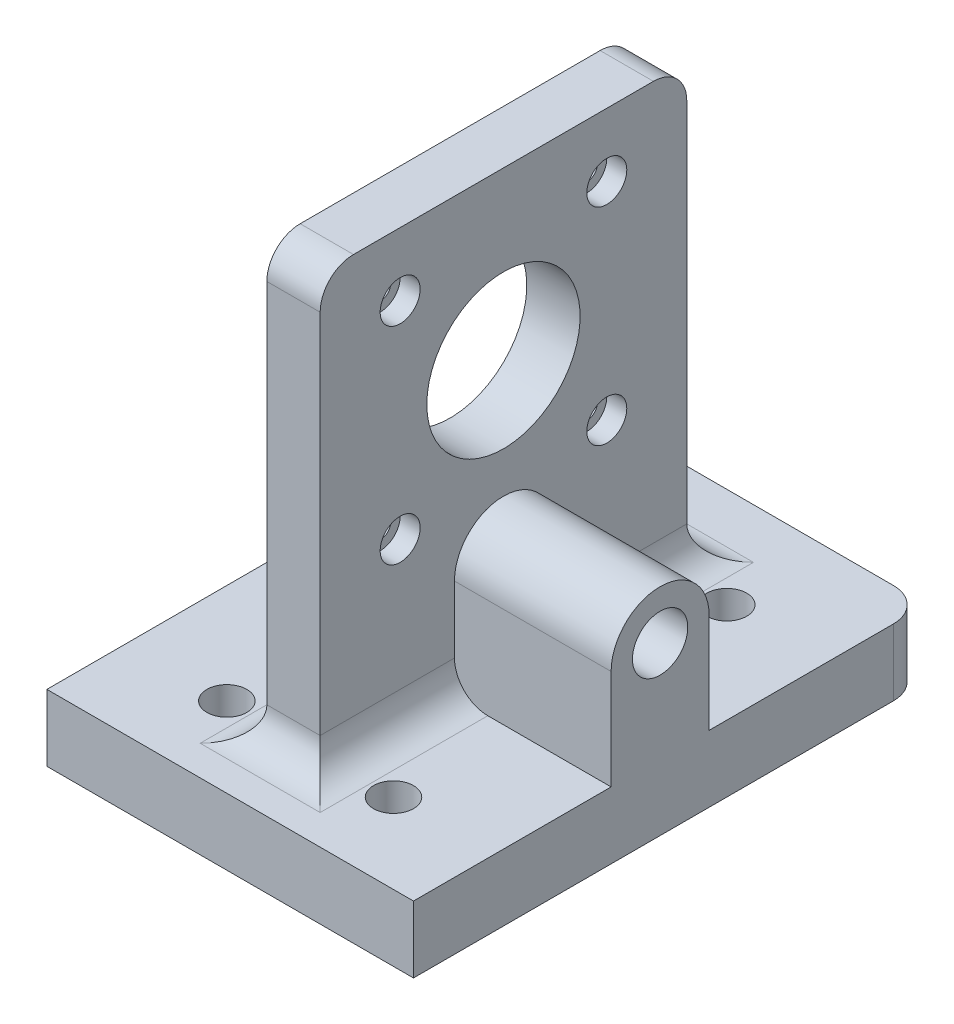
from build123d import *

# Parameters (mm, degrees)
SKETCH1_W               = 55
SKETCH1_H               = 80
BOSS_EXTRUDE1_DEPTH     = 10
SKETCH6_R               = 1.65
CUT_EXTRUDE2_DEPTH      = 55
LPATTERN1_COUNT         = 3
LPATTERN1_PITCH         = 25
MIRROR3_COPY_1_SKETCH_R = 1.65
MIRROR3_COPY_1_DEPTH    = 55
MIRROR3_COPY_2_SKETCH_R = 1.65
MIRROR3_COPY_2_DEPTH    = 55
SKETCH8_W               = 8
SKETCH8_H               = 55
BOSS_EXTRUDE3_DEPTH     = 65
FILLET3_R               = 5
SKETCH9_R               = 1.6
SKETCH9_R_2             = 11.5
CUT_EXTRUDE3_DEPTH      = 32.5
SKETCH10_R              = 3
CUT_EXTRUDE4_DEPTH      = 3
CUT_EXTRUDE5_START      = -5
SKETCH11_R              = 3
CUT_EXTRUDE5_DEPTH      = 71
LPATTERN2_COUNT         = 3
LPATTERN2_PITCH         = 25
MIRROR4_START           = -5
MIRROR4_COPY_1_SKETCH_R = 3
MIRROR4_COPY_1_DEPTH    = 71
MIRROR4_COPY_2_SKETCH_R = 3
MIRROR4_COPY_2_DEPTH    = 71
CUT_EXTRUDE6_DEPTH      = 10
SKETCH13_R              = 4.15
BOSS_EXTRUDE4_DEPTH     = 23.5


with BuildPart() as part:
    # Sketch1 → Boss-Extrude1 (new body)
    with BuildSketch(Plane(origin=(0, 0, 0), x_dir=(1, 0, 0), z_dir=(0, 1, 0))):
        Rectangle(SKETCH1_W, SKETCH1_H)
    extrude(amount=BOSS_EXTRUDE1_DEPTH)

    # Sketch6 → Cut-Extrude2 (cut)
    with BuildSketch(Plane(origin=(0, 10, 0), x_dir=(1, 0, 0), z_dir=(0, 1, 0))):
        with Locations((-12.5, -25)):
            Circle(SKETCH6_R)
    cut_extrude2 = extrude(amount=-CUT_EXTRUDE2_DEPTH, mode=Mode.SUBTRACT)

    # LPattern1: Cut-Extrude2 ×3
    with Locations(*[(0, 0, -i * LPATTERN1_PITCH) for i in range(1, LPATTERN1_COUNT)]):
        add(cut_extrude2, mode=Mode.SUBTRACT)

    # Mirror3: Cut-Extrude2 across plane
    add(cut_extrude2.mirror(Plane(origin=(0, 0, 0), x_dir=(0, 0, 1), z_dir=(1, 0, 0))), mode=Mode.SUBTRACT)

    # Mirror3 copy 1 sketch → Mirror3 copy 1 (cut)
    with BuildSketch(Plane(origin=(0, 10, -25), x_dir=(-1, 0, 0), z_dir=(0, 1, 0))):
        with Locations((-12.5, 25)):
            Circle(MIRROR3_COPY_1_SKETCH_R)
    extrude(amount=-MIRROR3_COPY_1_DEPTH, mode=Mode.SUBTRACT)

    # Mirror3 copy 2 sketch → Mirror3 copy 2 (cut)
    with BuildSketch(Plane(origin=(0, 10, -50), x_dir=(-1, 0, 0), z_dir=(0, 1, 0))):
        with Locations((-12.5, 25)):
            Circle(MIRROR3_COPY_2_SKETCH_R)
    extrude(amount=-MIRROR3_COPY_2_DEPTH, mode=Mode.SUBTRACT)

    # Sketch8 → Boss-Extrude3 (add)
    with BuildSketch(Plane(origin=(0, 10, 0), x_dir=(1, 0, 0), z_dir=(0, 1, 0))):
        Rectangle(SKETCH8_W, SKETCH8_H)
    extrude(amount=BOSS_EXTRUDE3_DEPTH)

    # Fillet3
    fillet3_edges = [part.edges().sort_by_distance(p)[0] for p in [
        (4, 10, 0),
        (0, 10, -27.5),
        (-4, 10, 0),
        (0, 10, 27.5),
        (0, 75, -27.5),
        (0, 75, 27.5),
        (-27.5, 5, -40),
        (27.5, 5, -40),
    ]]
    fillet(fillet3_edges, radius=FILLET3_R)

    # Sketch9 → Cut-Extrude3 (cut, through all)
    with BuildSketch(Plane.ZY.offset(4)):
        with Locations((-15.5, 65.5)):
            Circle(SKETCH9_R)
        with Locations((15.5, 65.5)):
            Circle(SKETCH9_R)
        with Locations((-15.5, 34.5)):
            Circle(SKETCH9_R)
        with Locations((15.5, 34.5)):
            Circle(SKETCH9_R)
        with Locations((0, 50)):
            Circle(SKETCH9_R_2)
    extrude(amount=-CUT_EXTRUDE3_DEPTH, mode=Mode.SUBTRACT)

    # Sketch10 → Cut-Extrude4 (cut)
    with BuildSketch(Plane(origin=(4, 0, 0), x_dir=(0, 0, -1), z_dir=(1, 0, 0))):
        with Locations((-15.5, 65.5)):
            Circle(SKETCH10_R)
        with Locations((15.5, 65.5)):
            Circle(SKETCH10_R)
        with Locations((15.5, 34.5)):
            Circle(SKETCH10_R)
        with Locations((-15.5, 34.5)):
            Circle(SKETCH10_R)
    extrude(amount=-CUT_EXTRUDE4_DEPTH, mode=Mode.SUBTRACT)

    # Sketch11 → Cut-Extrude5 (cut)
    with BuildSketch(Plane(origin=(0, 10, 0), x_dir=(1, 0, 0), z_dir=(0, 1, 0)).offset(CUT_EXTRUDE5_START)):
        with Locations((-12.5, -25)):
            Circle(SKETCH11_R)
    cut_extrude5 = extrude(amount=CUT_EXTRUDE5_DEPTH, mode=Mode.SUBTRACT)

    # LPattern2: Cut-Extrude5 ×3
    with Locations(*[(0, 0, -i * LPATTERN2_PITCH) for i in range(1, LPATTERN2_COUNT)]):
        add(cut_extrude5, mode=Mode.SUBTRACT)

    # Mirror4: Cut-Extrude5 across plane
    add(cut_extrude5.mirror(Plane(origin=(0, 0, 0), x_dir=(0, 0, 1), z_dir=(1, 0, 0))), mode=Mode.SUBTRACT)

    # Mirror4 copy 1 sketch → Mirror4 copy 1 (cut)
    with BuildSketch(Plane(origin=(0, 10, -25), x_dir=(-1, 0, 0), z_dir=(0, 1, 0)).offset(MIRROR4_START)):
        with Locations((-12.5, 25)):
            Circle(MIRROR4_COPY_1_SKETCH_R)
    extrude(amount=MIRROR4_COPY_1_DEPTH, mode=Mode.SUBTRACT)

    # Mirror4 copy 2 sketch → Mirror4 copy 2 (cut)
    with BuildSketch(Plane(origin=(0, 10, -50), x_dir=(-1, 0, 0), z_dir=(0, 1, 0)).offset(MIRROR4_START)):
        with Locations((-12.5, 25)):
            Circle(MIRROR4_COPY_2_SKETCH_R)
    extrude(amount=MIRROR4_COPY_2_DEPTH, mode=Mode.SUBTRACT)

    # Sketch12 → Cut-Extrude6 (cut)
    with BuildSketch(Plane(origin=(0, 10, 0), x_dir=(1, 0, 0), z_dir=(0, 1, 0))):
        Polygon((12.5, -37), (-38.055736231, -37), (-38.055736231, -44.287300659), (40.369344369, -44.287300659), (40.369344369, -37), align=None)
    extrude(amount=-CUT_EXTRUDE6_DEPTH, mode=Mode.SUBTRACT)

    # Sketch13 → Boss-Extrude4 (add)
    with BuildSketch(Plane(origin=(4, 0, 0), x_dir=(0, 0, -1), z_dir=(1, 0, 0))):
        with BuildLine():
            Line((-7.35, 25), (-7.35, 10))
            Line((-7.35, 10), (-7.35, 0))
            Line((-7.35, 0), (7.35, 0))
            Line((7.35, 0), (7.35, 10))
            Line((7.35, 10), (7.35, 25))
            ThreePointArc((7.35, 25), (0, 32.35), (-7.35, 25))
        make_face()
        with Locations((0, 25)):
            Circle(SKETCH13_R, mode=Mode.SUBTRACT)
    extrude(amount=BOSS_EXTRUDE4_DEPTH)


solid = part.part
